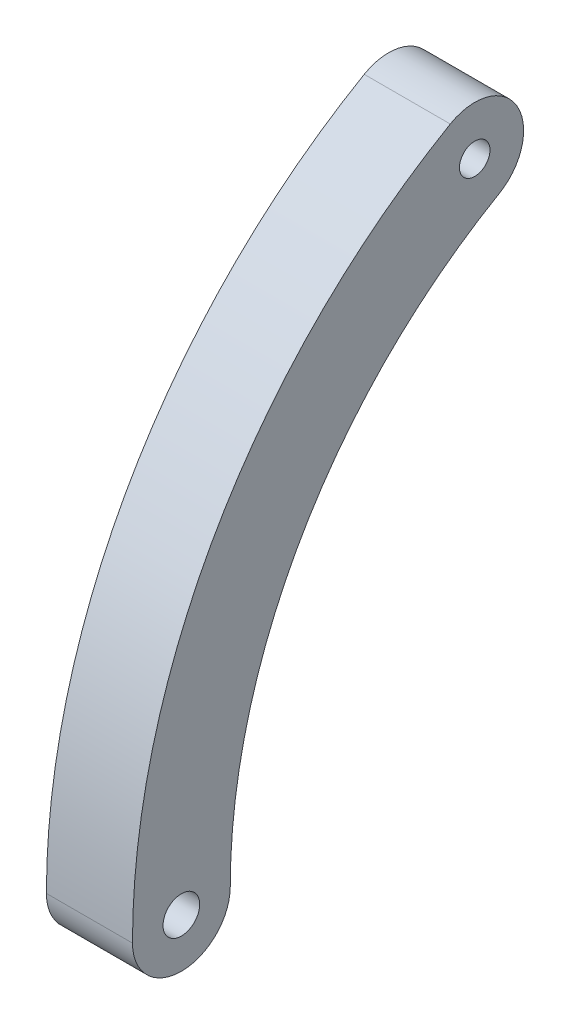
from build123d import *

# Parameters (mm, degrees)
ESQUISSE1_R        = 1.190625
ESQUISSE1_R_2      = 0.9921875
BOSS_EXTRU_1_DEPTH = 5.588


with BuildPart() as part:
    # Esquisse1 → Boss.-Extru.1 (new body)
    with BuildSketch(Plane(origin=(0, 0, 0), x_dir=(0, 0, -1), z_dir=(1, 0, 0))):
        with BuildLine():
            ThreePointArc((-34.925, 0), (-30.245937227, 17.4625), (-17.4625, 30.245937227))
            ThreePointArc((-17.4625, 30.245937227), (-16.300369343, 34.583067884), (-20.6375, 35.745198541))
            ThreePointArc((-20.6375, 35.745198541), (-35.745198541, 20.6375), (-41.275, 0))
            ThreePointArc((-41.275, 0), (-38.1, -3.175), (-34.925, 0))
        make_face()
        with Locations((-38.1, 0)):
            Circle(ESQUISSE1_R, mode=Mode.SUBTRACT)
        with Locations((-19.05, 32.995567884)):
            Circle(ESQUISSE1_R_2, mode=Mode.SUBTRACT)
    extrude(amount=BOSS_EXTRU_1_DEPTH)


solid = part.part
